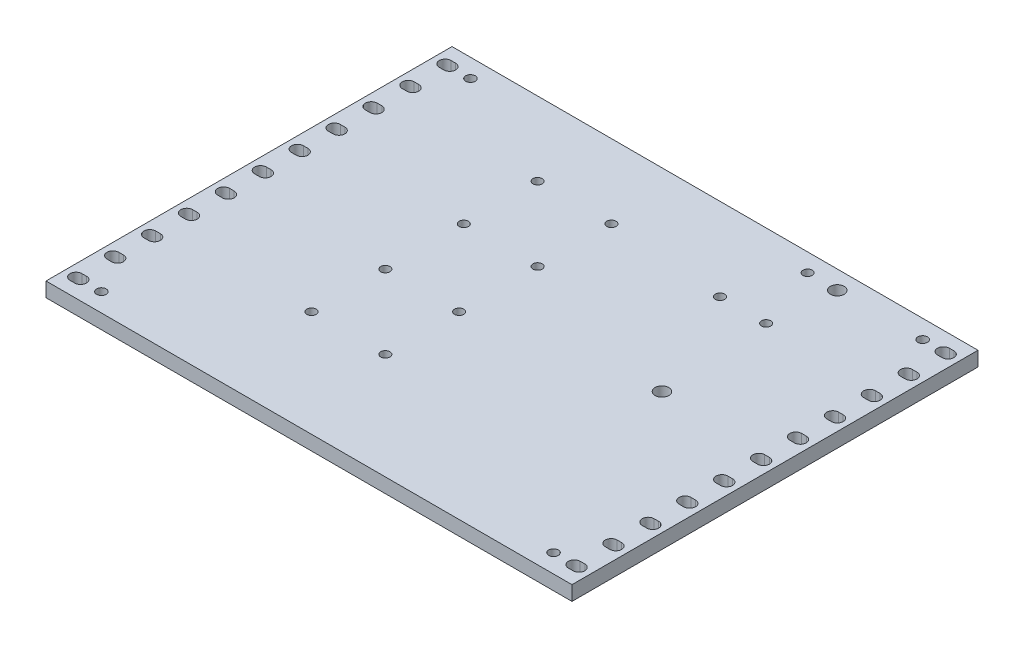
from build123d import *

# Parameters (mm, degrees)
BOSS_EXTRUDE1_DEPTH     = 10
CUT_EXTRUDE1_DEPTH      = 1
CUT_EXTRUDE1_DEPTH_BACK = 11
SKETCH4_R               = 4.7625
CUT_EXTRUDE2_DEPTH      = 11
SKETCH5_R               = 3.175
CUT_EXTRUDE3_DEPTH      = 11
SKETCH6_R               = 3.175
CUT_EXTRUDE4_DEPTH      = 11
SKETCH7_R               = 3.302
CUT_EXTRUDE5_DEPTH      = 11


with BuildPart() as part:
    # Sketch1 → Boss-Extrude1 (new body)
    with BuildSketch(Plane(origin=(0, 0, 0), x_dir=(1, 0, 0), z_dir=(0, 1, 0))):
        Polygon((0, 279.4), (0, 0), (38.1, 0), (292.1, 0), (361.95, 0), (361.95, 279.4), align=None)
    extrude(amount=BOSS_EXTRUDE1_DEPTH)

    # Sketch2 → Cut-Extrude1 (cut, two sides)
    with BuildSketch(Plane(origin=(0, 10, 0), x_dir=(1, 0, 0), z_dir=(0, 1, 0))) as cut_extrude1_sk:
        with BuildLine():
            Line((350.8375, 270.764), (354.0125, 270.764))
            ThreePointArc((354.0125, 270.764), (358.0765, 266.7), (354.0125, 262.636))
            Line((354.0125, 262.636), (350.8375, 262.636))
            ThreePointArc((350.8375, 262.636), (346.7735, 266.7), (350.8375, 270.764))
        make_face()
        with BuildLine():
            Line((350.8375, 245.364), (354.0125, 245.364))
            ThreePointArc((354.0125, 245.364), (358.0765, 241.3), (354.0125, 237.236))
            Line((354.0125, 237.236), (350.8375, 237.236))
            ThreePointArc((350.8375, 237.236), (346.7735, 241.3), (350.8375, 245.364))
        make_face()
        with BuildLine():
            Line((350.8375, 219.964), (354.0125, 219.964))
            ThreePointArc((354.0125, 219.964), (358.0765, 215.9), (354.0125, 211.836))
            Line((354.0125, 211.836), (350.8375, 211.836))
            ThreePointArc((350.8375, 211.836), (346.7735, 215.9), (350.8375, 219.964))
        make_face()
        with BuildLine():
            Line((350.8375, 194.564), (354.0125, 194.564))
            ThreePointArc((354.0125, 194.564), (358.0765, 190.5), (354.0125, 186.436))
            Line((354.0125, 186.436), (350.8375, 186.436))
            ThreePointArc((350.8375, 186.436), (346.7735, 190.5), (350.8375, 194.564))
        make_face()
        with BuildLine():
            Line((350.8375, 169.164), (354.0125, 169.164))
            ThreePointArc((354.0125, 169.164), (358.0765, 165.1), (354.0125, 161.036))
            Line((354.0125, 161.036), (350.8375, 161.036))
            ThreePointArc((350.8375, 161.036), (346.7735, 165.1), (350.8375, 169.164))
        make_face()
        with BuildLine():
            Line((350.8375, 143.764), (354.0125, 143.764))
            ThreePointArc((354.0125, 143.764), (358.0765, 139.7), (354.0125, 135.636))
            Line((354.0125, 135.636), (350.8375, 135.636))
            ThreePointArc((350.8375, 135.636), (346.7735, 139.7), (350.8375, 143.764))
        make_face()
        with BuildLine():
            Line((350.8375, 118.364), (354.0125, 118.364))
            ThreePointArc((354.0125, 118.364), (358.0765, 114.3), (354.0125, 110.236))
            Line((354.0125, 110.236), (350.8375, 110.236))
            ThreePointArc((350.8375, 110.236), (346.7735, 114.3), (350.8375, 118.364))
        make_face()
        with BuildLine():
            Line((350.8375, 92.964), (354.0125, 92.964))
            ThreePointArc((354.0125, 92.964), (358.0765, 88.9), (354.0125, 84.836))
            Line((354.0125, 84.836), (350.8375, 84.836))
            ThreePointArc((350.8375, 84.836), (346.7735, 88.9), (350.8375, 92.964))
        make_face()
        with BuildLine():
            Line((350.8375, 67.564), (354.0125, 67.564))
            ThreePointArc((354.0125, 67.564), (358.0765, 63.5), (354.0125, 59.436))
            Line((354.0125, 59.436), (350.8375, 59.436))
            ThreePointArc((350.8375, 59.436), (346.7735, 63.5), (350.8375, 67.564))
        make_face()
        with BuildLine():
            Line((350.8375, 42.164), (354.0125, 42.164))
            ThreePointArc((354.0125, 42.164), (358.0765, 38.1), (354.0125, 34.036))
            Line((354.0125, 34.036), (350.8375, 34.036))
            ThreePointArc((350.8375, 34.036), (346.7735, 38.1), (350.8375, 42.164))
        make_face()
        with BuildLine():
            Line((350.8375, 16.764), (354.0125, 16.764))
            ThreePointArc((354.0125, 16.764), (358.0765, 12.7), (354.0125, 8.636))
            Line((354.0125, 8.636), (350.8375, 8.636))
            ThreePointArc((350.8375, 8.636), (346.7735, 12.7), (350.8375, 16.764))
        make_face()
        with BuildLine():
            Line((11.1125, 270.764), (7.9375, 270.764))
            ThreePointArc((7.9375, 270.764), (3.8735, 266.7), (7.9375, 262.636))
            Line((7.9375, 262.636), (11.1125, 262.636))
            ThreePointArc((11.1125, 262.636), (15.1765, 266.7), (11.1125, 270.764))
        make_face()
        with BuildLine():
            Line((11.1125, 16.764), (7.9375, 16.764))
            ThreePointArc((7.9375, 16.764), (3.8735, 12.7), (7.9375, 8.636))
            Line((7.9375, 8.636), (11.1125, 8.636))
            ThreePointArc((11.1125, 8.636), (15.1765, 12.7), (11.1125, 16.764))
        make_face()
        with BuildLine():
            Line((11.1125, 42.164), (7.9375, 42.164))
            ThreePointArc((7.9375, 42.164), (3.8735, 38.1), (7.9375, 34.036))
            Line((7.9375, 34.036), (11.1125, 34.036))
            ThreePointArc((11.1125, 34.036), (15.1765, 38.1), (11.1125, 42.164))
        make_face()
        with BuildLine():
            Line((11.1125, 67.564), (7.9375, 67.564))
            ThreePointArc((7.9375, 67.564), (3.8735, 63.5), (7.9375, 59.436))
            Line((7.9375, 59.436), (11.1125, 59.436))
            ThreePointArc((11.1125, 59.436), (15.1765, 63.5), (11.1125, 67.564))
        make_face()
        with BuildLine():
            Line((11.1125, 92.964), (7.9375, 92.964))
            ThreePointArc((7.9375, 92.964), (3.8735, 88.9), (7.9375, 84.836))
            Line((7.9375, 84.836), (11.1125, 84.836))
            ThreePointArc((11.1125, 84.836), (15.1765, 88.9), (11.1125, 92.964))
        make_face()
        with BuildLine():
            Line((11.1125, 118.364), (7.9375, 118.364))
            ThreePointArc((7.9375, 118.364), (3.8735, 114.3), (7.9375, 110.236))
            Line((7.9375, 110.236), (11.1125, 110.236))
            ThreePointArc((11.1125, 110.236), (15.1765, 114.3), (11.1125, 118.364))
        make_face()
        with BuildLine():
            Line((11.1125, 143.764), (7.9375, 143.764))
            ThreePointArc((7.9375, 143.764), (3.8735, 139.7), (7.9375, 135.636))
            Line((7.9375, 135.636), (11.1125, 135.636))
            ThreePointArc((11.1125, 135.636), (15.1765, 139.7), (11.1125, 143.764))
        make_face()
        with BuildLine():
            Line((11.1125, 169.164), (7.9375, 169.164))
            ThreePointArc((7.9375, 169.164), (3.8735, 165.1), (7.9375, 161.036))
            Line((7.9375, 161.036), (11.1125, 161.036))
            ThreePointArc((11.1125, 161.036), (15.1765, 165.1), (11.1125, 169.164))
        make_face()
        with BuildLine():
            Line((11.1125, 194.564), (7.9375, 194.564))
            ThreePointArc((7.9375, 194.564), (3.8735, 190.5), (7.9375, 186.436))
            Line((7.9375, 186.436), (11.1125, 186.436))
            ThreePointArc((11.1125, 186.436), (15.1765, 190.5), (11.1125, 194.564))
        make_face()
        with BuildLine():
            Line((11.1125, 219.964), (7.9375, 219.964))
            ThreePointArc((7.9375, 219.964), (3.8735, 215.9), (7.9375, 211.836))
            Line((7.9375, 211.836), (11.1125, 211.836))
            ThreePointArc((11.1125, 211.836), (15.1765, 215.9), (11.1125, 219.964))
        make_face()
        with BuildLine():
            Line((11.1125, 245.364), (7.9375, 245.364))
            ThreePointArc((7.9375, 245.364), (3.8735, 241.3), (7.9375, 237.236))
            Line((7.9375, 237.236), (11.1125, 237.236))
            ThreePointArc((11.1125, 237.236), (15.1765, 241.3), (11.1125, 245.364))
        make_face()
    extrude(amount=CUT_EXTRUDE1_DEPTH, mode=Mode.SUBTRACT)
    extrude(cut_extrude1_sk.sketch, amount=-CUT_EXTRUDE1_DEPTH_BACK, mode=Mode.SUBTRACT)

    # Sketch4 → Cut-Extrude2 (cut, through all)
    with BuildSketch(Plane.XZ):
        with Locations((277.8125, -266.7)):
            Circle(SKETCH4_R)
        with Locations((277.8125, -146.05)):
            Circle(SKETCH4_R)
    extrude(amount=-CUT_EXTRUDE2_DEPTH, mode=Mode.SUBTRACT)

    # Sketch5 → Cut-Extrude3 (cut, through all)
    with BuildSketch(Plane.XZ):
        with Locations((257.175, -266.944116923)):
            Circle(SKETCH5_R)
        with Locations((273.05, -222.494116923)):
            Circle(SKETCH5_R)
        with Locations((241.3, -222.494116923)):
            Circle(SKETCH5_R)
    extrude(amount=-CUT_EXTRUDE3_DEPTH, mode=Mode.SUBTRACT)

    # Sketch6 → Cut-Extrude4 (cut, through all)
    with BuildSketch(Plane.XZ):
        with Locations((109.696959753, -228.6)):
            Circle(SKETCH6_R)
        with Locations((109.696959753, -177.8)):
            Circle(SKETCH6_R)
        with Locations((109.696959753, -123.825)):
            Circle(SKETCH6_R)
        with Locations((109.696959753, -73.025)):
            Circle(SKETCH6_R)
        with Locations((160.496959753, -228.6)):
            Circle(SKETCH6_R)
        with Locations((160.496959753, -177.8)):
            Circle(SKETCH6_R)
        with Locations((160.496959753, -123.825)):
            Circle(SKETCH6_R)
        with Locations((160.496959753, -73.025)):
            Circle(SKETCH6_R)
    extrude(amount=-CUT_EXTRUDE4_DEPTH, mode=Mode.SUBTRACT)

    # Sketch7 → Cut-Extrude5 (cut, through all)
    with BuildSketch(Plane.XZ):
        with Locations((25.4, -266.7)):
            Circle(SKETCH7_R)
        with Locations((336.55, -266.7)):
            Circle(SKETCH7_R)
        with Locations((336.55, -12.7)):
            Circle(SKETCH7_R)
        with Locations((25.4, -12.7)):
            Circle(SKETCH7_R)
    extrude(amount=-CUT_EXTRUDE5_DEPTH, mode=Mode.SUBTRACT)


solid = part.part
